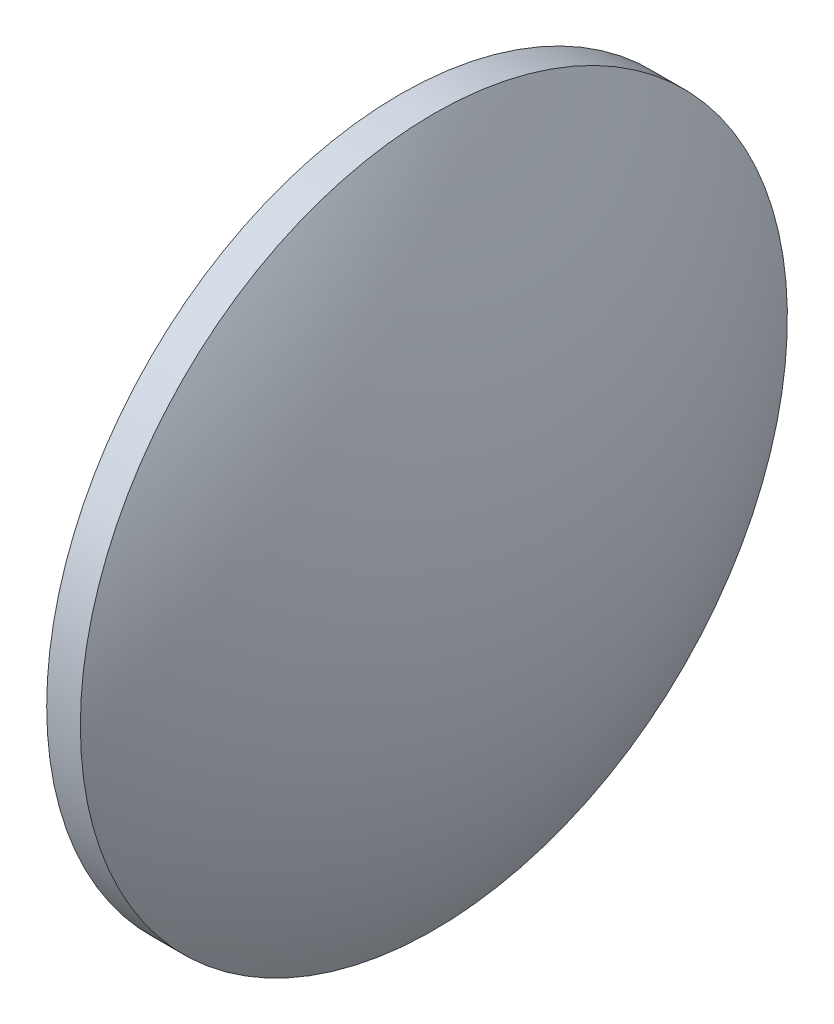
from build123d import *

# Parameters (mm, degrees)
SKETCH_1_ONE_SIDE_W = 3
SKETCH_1_ONE_SIDE_H = 31.500126001


with BuildPart() as part:
    # 草图1 one side → 旋转1 (revolve)
    with BuildSketch(Plane.XY):
        with Locations((214.444409266, 136.333817794)):
            Rectangle(SKETCH_1_ONE_SIDE_W, SKETCH_1_ONE_SIDE_H)
        with BuildLine():
            Line((204.24538847, 120.583754794), (212.944409266, 120.583754794))
            Line((212.944409266, 120.583754794), (212.944409266, 152.083880795))
            ThreePointArc((212.944409266, 152.083880795), (206.460097704, 136.923360824), (204.24538847, 120.583754794))
        make_face()
        with BuildLine():
            Line((215.944409266, 120.583754794), (224.643430062, 120.583754794))
            ThreePointArc((224.643430062, 120.583754794), (222.428720828, 136.923360824), (215.944409266, 152.083880795))
            Line((215.944409266, 152.083880795), (215.944409266, 120.583754794))
        make_face()
    revolve(axis=Axis((199.006399593, 120.583754794, 0), (1, 0, 0)))


solid = part.part
